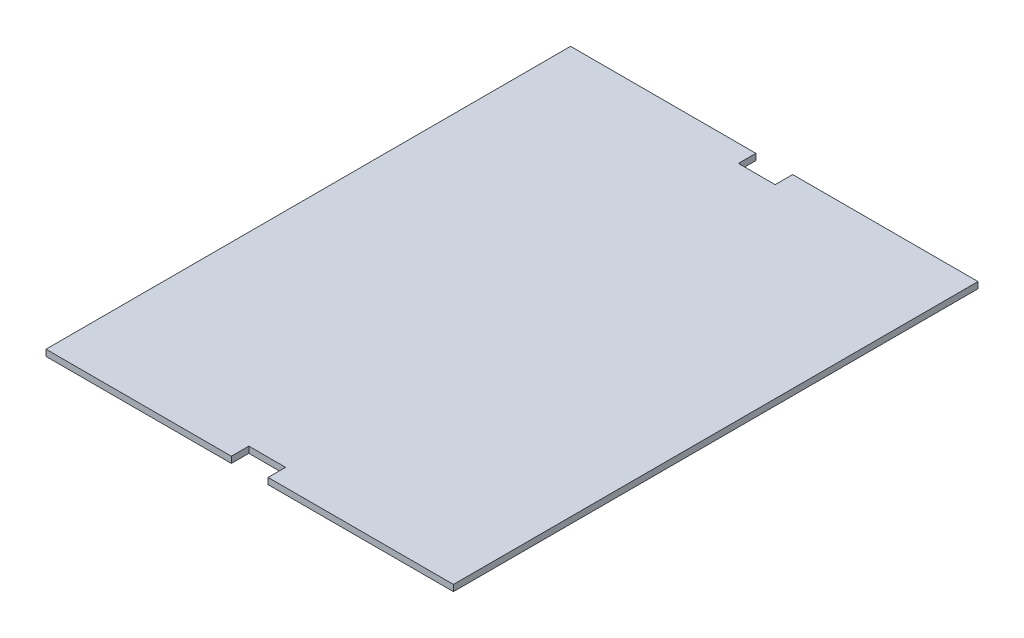
from build123d import *

# Parameters (mm, degrees)
CROQUIS1_W              = 116.5
CROQUIS1_H              = 150
SALIENTE_EXTRUIR1_DEPTH = 1.8
CROQUIS2_W              = 10.5
CROQUIS2_H              = 5
CORTAR_EXTRUIR1_DEPTH   = 2.8


with BuildPart() as part:
    # Croquis1 → Saliente-Extruir1 (new body)
    with BuildSketch(Plane(origin=(0, 0, 0), x_dir=(1, 0, 0), z_dir=(0, 1, 0))):
        Rectangle(CROQUIS1_W, CROQUIS1_H)
    extrude(amount=SALIENTE_EXTRUIR1_DEPTH)

    # Croquis2 → Cortar-Extruir1 (cut, through all)
    with BuildSketch(Plane(origin=(0, 1.8, 0), x_dir=(1, 0, 0), z_dir=(0, 1, 0))):
        with Locations((0, -72.5)):
            Rectangle(CROQUIS2_W, CROQUIS2_H)
        with Locations((0, 72.5)):
            Rectangle(CROQUIS2_W, CROQUIS2_H)
    extrude(amount=-CORTAR_EXTRUIR1_DEPTH, mode=Mode.SUBTRACT)


solid = part.part
